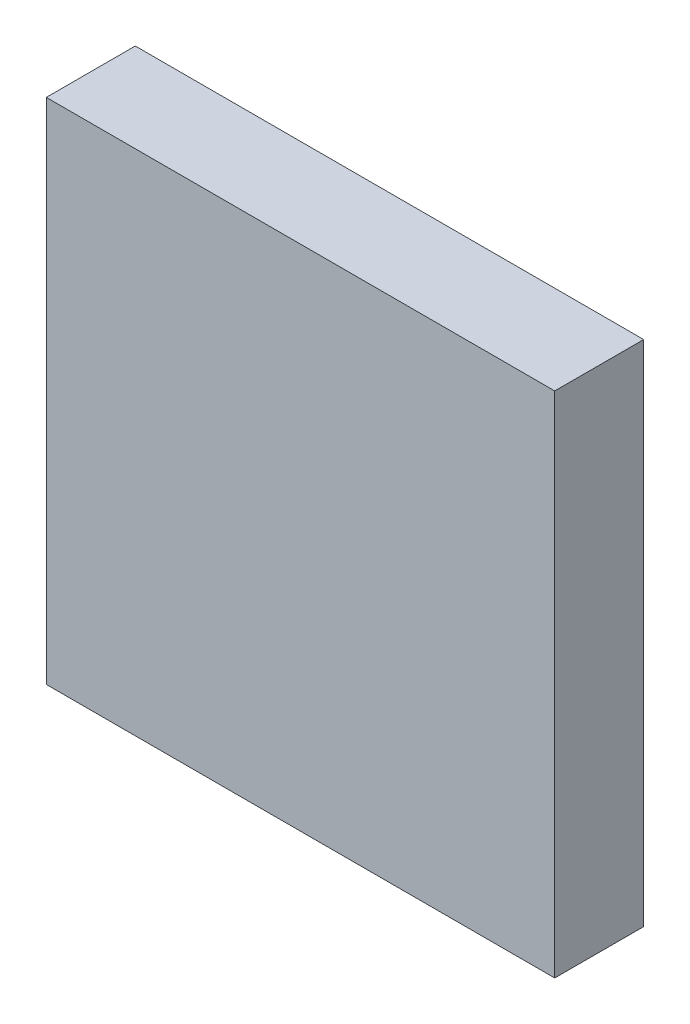
from build123d import *

# Parameters (mm, degrees)
SKETCH1_W           = 2000
SKETCH1_H           = 2000
SKETCH1_W_2         = 1900
SKETCH1_H_2         = 1900
SKETCH1_H_3         = 50
BOSS_EXTRUDE1_DEPTH = 300
SKETCH2_W           = 2000
SKETCH2_H           = 2000
BOSS_EXTRUDE2_DEPTH = 50


with BuildPart() as part:
    # Sketch1 → Boss-Extrude1 (new body)
    with BuildSketch(Plane.XY):
        Rectangle(SKETCH1_W, SKETCH1_H)
        Rectangle(SKETCH1_W_2, SKETCH1_H_2, mode=Mode.SUBTRACT)
        with Locations((0, 625)):
            Rectangle(SKETCH1_W_2, SKETCH1_H_3)
        with Locations((0, 274.988)):
            Rectangle(SKETCH1_W_2, SKETCH1_H_3)
        with Locations((0, -75.024)):
            Rectangle(SKETCH1_W_2, SKETCH1_H_3)
        with Locations((0, -425.036)):
            Rectangle(SKETCH1_W_2, SKETCH1_H_3)
        with Locations((0, -775.048)):
            Rectangle(SKETCH1_W_2, SKETCH1_H_3)
    extrude(amount=BOSS_EXTRUDE1_DEPTH)

    # Sketch2 → Boss-Extrude2 (add)
    with BuildSketch(Plane.XY.offset(300)):
        Rectangle(SKETCH2_W, SKETCH2_H)
    extrude(amount=BOSS_EXTRUDE2_DEPTH)


solid = part.part
